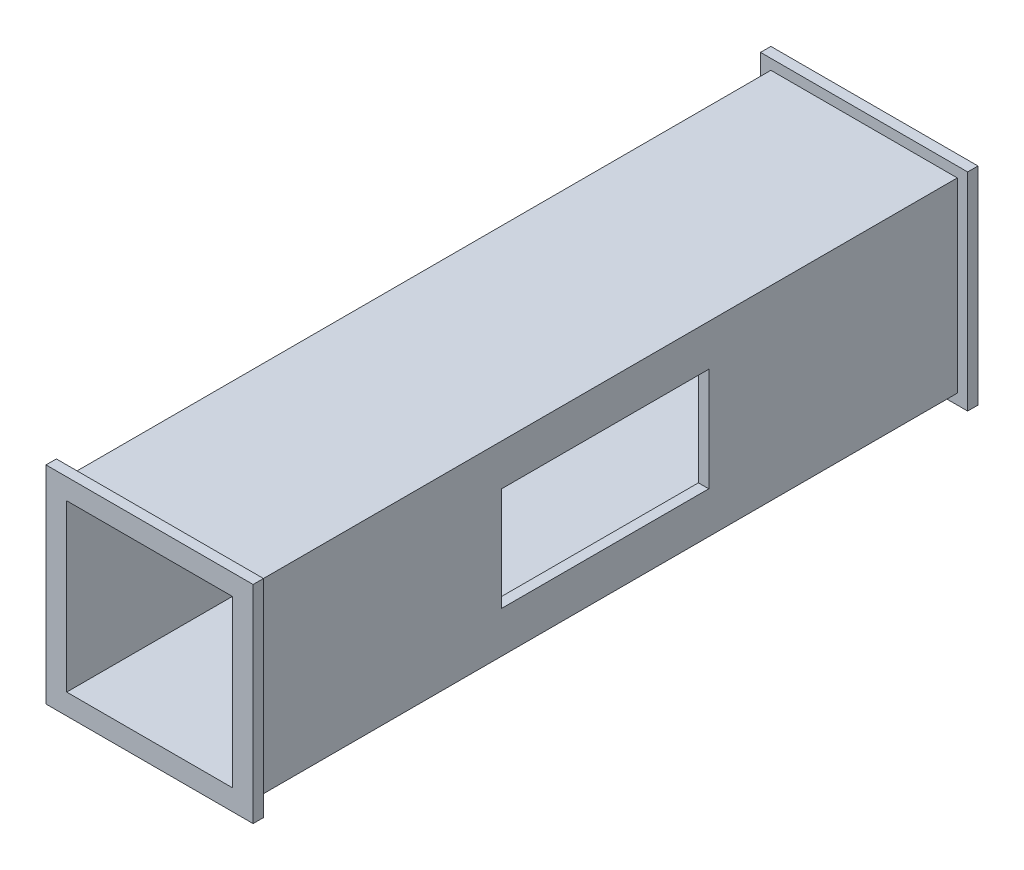
from build123d import *

# Parameters (mm, degrees)
SKETCH3_W           = 90
SKETCH3_H           = 90
BOSS_EXTRUDE1_DEPTH = 350
SHELL1_T            = -5
SKETCH4_W           = 100
SKETCH4_H           = 50
CUT_EXTRUDE1_DEPTH  = 20
SKETCH5_W           = 100
SKETCH5_H           = 100
SKETCH5_W_2         = 90
SKETCH5_H_2         = 90
BOSS_EXTRUDE2_DEPTH = 5
SKETCH6_W           = 100
SKETCH6_H           = 100
SKETCH6_W_2         = 90
SKETCH6_H_2         = 90
BOSS_EXTRUDE3_DEPTH = 5


with BuildPart() as part:
    # Sketch3 → Boss-Extrude1 (new body)
    with BuildSketch(Plane.XY):
        Rectangle(SKETCH3_W, SKETCH3_H)
    extrude(amount=BOSS_EXTRUDE1_DEPTH)

    # Shell1
    shell1_openings = [part.faces().sort_by_distance(p)[0] for p in [
        (0, 0, 350),
        (0, 0, 0),
    ]]
    offset(amount=SHELL1_T, openings=shell1_openings, kind=Kind.INTERSECTION)

    # Sketch4 → Cut-Extrude1 (cut)
    with BuildSketch(Plane(origin=(45, 0, 0), x_dir=(0, 0, -1), z_dir=(1, 0, 0))):
        with Locations((-175, 0)):
            Rectangle(SKETCH4_W, SKETCH4_H)
    extrude(amount=-CUT_EXTRUDE1_DEPTH, mode=Mode.SUBTRACT)

    # Sketch5 → Boss-Extrude2 (add)
    with BuildSketch(Plane.XY.offset(350)):
        Rectangle(SKETCH5_W, SKETCH5_H)
        Rectangle(SKETCH5_W_2, SKETCH5_H_2, mode=Mode.SUBTRACT)
    extrude(amount=-BOSS_EXTRUDE2_DEPTH)

    # Sketch6 → Boss-Extrude3 (add)
    with BuildSketch(Plane(origin=(0, 0, 0), x_dir=(-1, 0, 0), z_dir=(0, 0, -1))):
        Rectangle(SKETCH6_W, SKETCH6_H)
        Rectangle(SKETCH6_W_2, SKETCH6_H_2, mode=Mode.SUBTRACT)
    extrude(amount=-BOSS_EXTRUDE3_DEPTH)


solid = part.part
